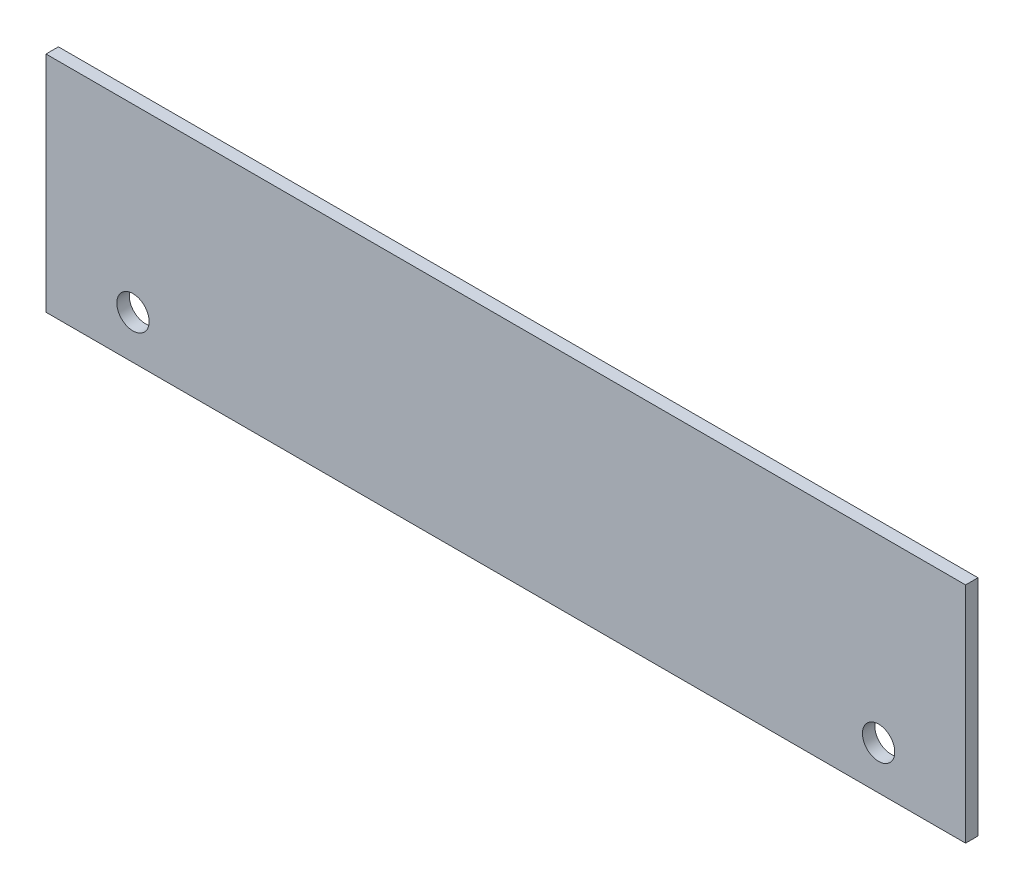
from build123d import *

# Parameters (mm, degrees)
SKETCH1_W           = 370
SKETCH1_H           = 90
BOSS_EXTRUDE1_DEPTH = 5
SKETCH2_R           = 6.5
CUT_EXTRUDE1_DEPTH  = 10


with BuildPart() as part:
    # Sketch1 → Boss-Extrude1 (new body)
    with BuildSketch(Plane.XY):
        Rectangle(SKETCH1_W, SKETCH1_H)
    extrude(amount=BOSS_EXTRUDE1_DEPTH)

    # Sketch2 → Cut-Extrude1 (cut)
    with BuildSketch(Plane.XY.offset(5)):
        with Locations((150, -27.5)):
            Circle(SKETCH2_R)
        with Locations((-150, -27.5)):
            Circle(SKETCH2_R)
    extrude(amount=-CUT_EXTRUDE1_DEPTH, mode=Mode.SUBTRACT)


solid = part.part
